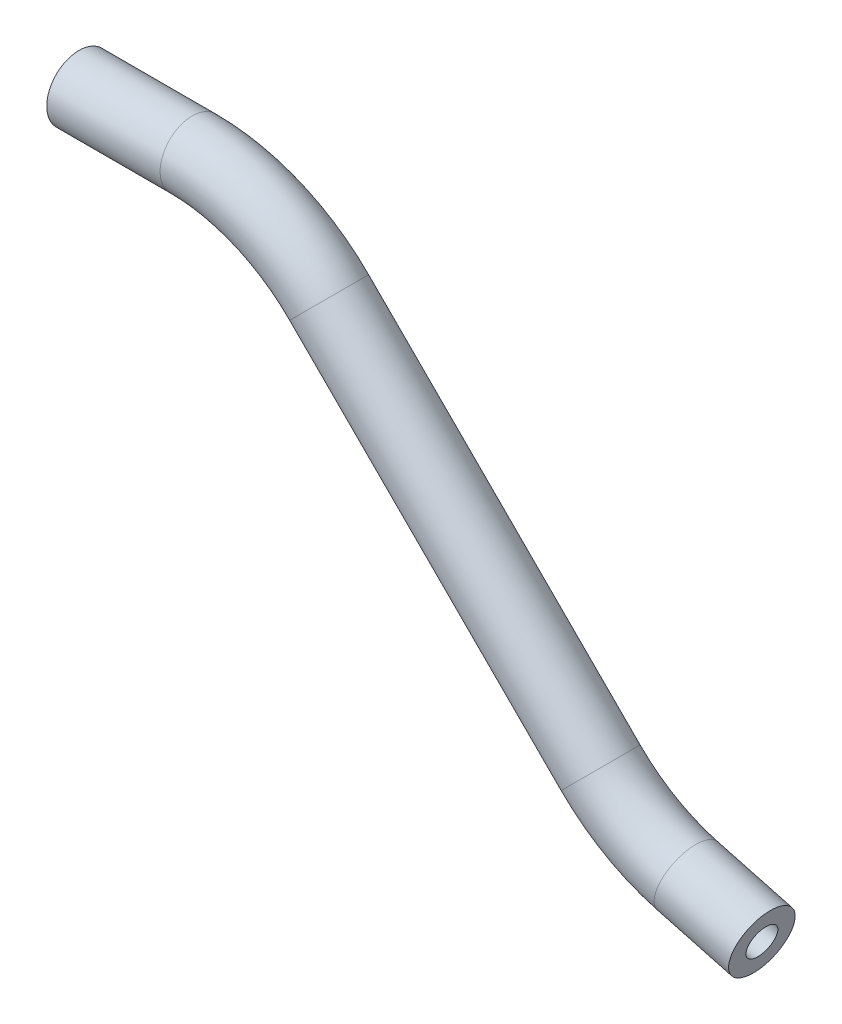
from build123d import *

# Parameters (mm, degrees)
SKETCH2_R   = 3.175
SKETCH2_R_2 = 1.524


with BuildPart() as part:
    # Sweep1: sweep along a path in Sketch1
    with BuildLine(Plane.XY) as sweep1_path:
        Line((0, 0), (11.159231637, 0))
        ThreePointArc((11.159231637, 0), (18.449351023, -1.450094906), (24.629615818, -5.579615818))
        Line((24.629615818, -5.579615818), (51.361645921, -32.311645921))
        ThreePointArc((51.361645921, -32.311645921), (55.307030103, -35.339045682), (59.901527293, -37.24214873))
        Line((59.901527293, -37.24214873), (67.238282478, -39.208026357))
    # Sketch2 → Sweep1 (sweep)
    with BuildSketch(Plane(origin=(0, 0, 0), x_dir=(0, 0, -1), z_dir=(1, 0, 0))):
        Circle(SKETCH2_R)
        Circle(SKETCH2_R_2, mode=Mode.SUBTRACT)
    sweep(path=sweep1_path.line)


solid = part.part
